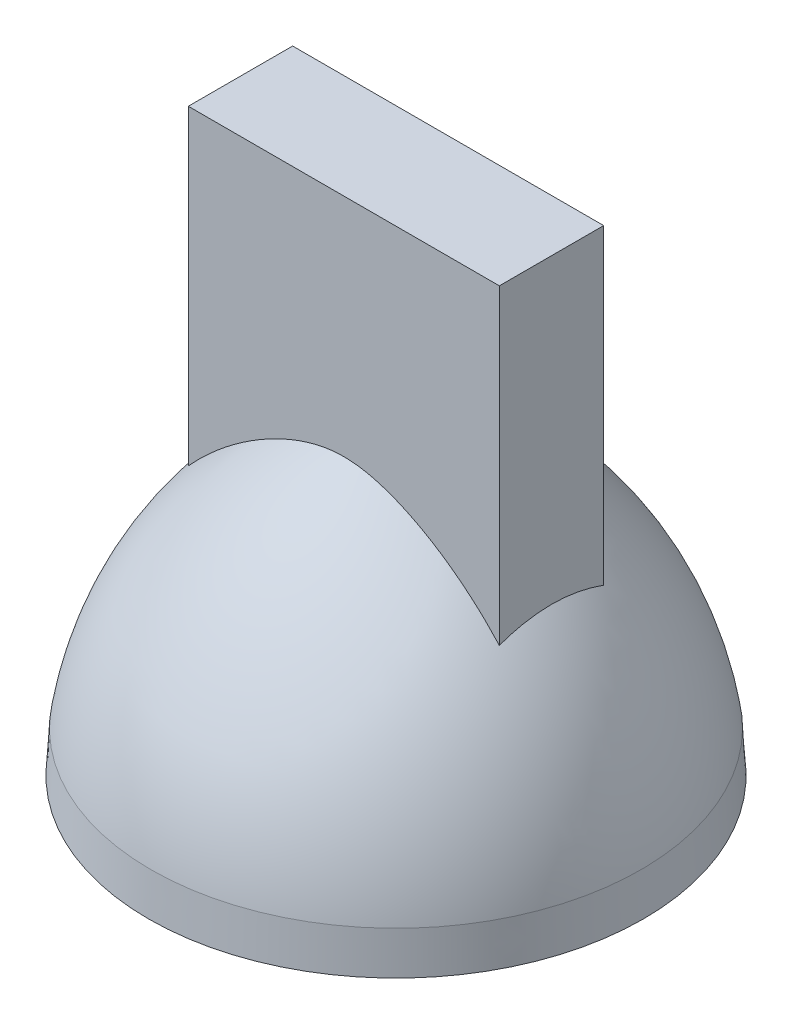
from build123d import *

# Parameters (mm, degrees)
BOSS_EXTRU_2_REACH             = 10
ESQUISSE3_W                    = 7.493865796
ESQUISSE3_H                    = 2.51391664
BOSS_EXTRU_2_DIRECTION_2_DEPTH = 5


with BuildPart() as part:
    # Esquisse1 → R_volution2 (revolve)
    with BuildSketch(Plane(origin=(0, 0, 0), x_dir=(0, 0, -1), z_dir=(1, 0, 0)), mode=Mode.PRIVATE) as r_volution2_sk:
        with BuildLine():
            Line((0, 7), (0, 8))
            Line((0, 8), (1, 7.681145748))
            ThreePointArc((1, 7.681145748), (4.273107431, 5.101924854), (5.903887779, 1.267062649))
            Line((5.903887779, 1.267062649), (5.963189718, 0.268822557))
            Line((5.963189718, 0.268822557), (5, 0))
            ThreePointArc((5, 0), (3.621627687, 4.301162634), (0, 7))
        make_face()
    revolve(r_volution2_sk.sketch.rotate(Axis((0, 19.327032319, 0), (0, -1, 0)), 180), axis=Axis((0, 19.327032319, 0), (0, -1, 0)))  # turned: the seam where the file's is

    # Esquisse3 → Boss.-Extru.2 (add, up to next)
    with BuildSketch(Plane(origin=(0, 8, 0), x_dir=(-1, 0, 0), z_dir=(0, -1, 0)), mode=Mode.PRIVATE) as boss_extru_2_sk1:
        Rectangle(ESQUISSE3_W, ESQUISSE3_H)
    boss_extru_2_tool1 = extrude(boss_extru_2_sk1.sketch, amount=BOSS_EXTRU_2_REACH, mode=Mode.PRIVATE) - part.part
    add(boss_extru_2_tool1.solids().sort_by_distance((0, 8, 0))[0])

    # Esquisse3 → Boss.-Extru.2 direction 2 (add)
    with BuildSketch(Plane(origin=(0, 8, 0), x_dir=(-1, 0, 0), z_dir=(0, -1, 0))):
        Rectangle(ESQUISSE3_W, ESQUISSE3_H)
    extrude(amount=-BOSS_EXTRU_2_DIRECTION_2_DEPTH)


solid = part.part
